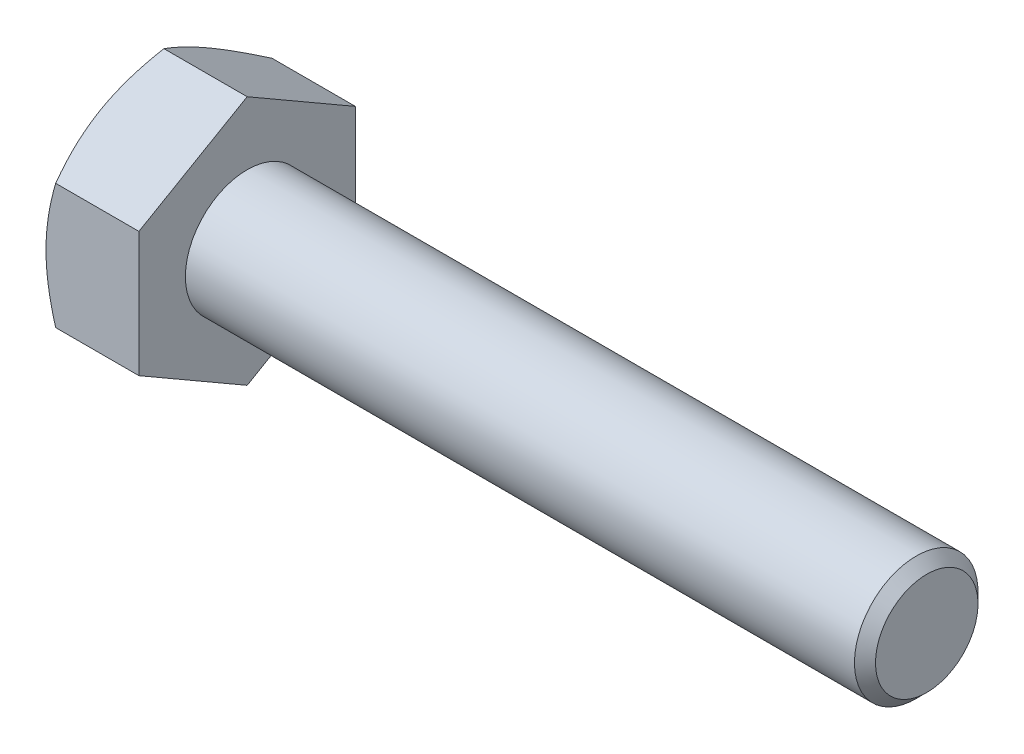
from build123d import *

# Parameters (mm, degrees)
BASEHEAD_DEPTH = 4.7752


with BuildPart() as part:
    # Sketch1 → BaseHead (new body)
    with BuildSketch(Plane(origin=(0, 0, 0), x_dir=(0, 0, -1), z_dir=(1, 0, 0))):
        Polygon((5.5626, 3.211568607), (5.5626, -3.211568607), (0, -6.423137215), (-5.5626, -3.211568607), (-5.5626, 3.211568607), (0, 6.423137215), align=None)
    extrude(amount=BASEHEAD_DEPTH)

    # BodySke → BaseBody (revolve)
    with BuildSketch(Plane.XY):
        Polygon((0, 0), (39.7002, 0), (39.7002, 2.63398), (39.15918, 3.175), (0, 3.175), align=None)
    revolve(axis=Axis((0, 0, 0), (1, 0, 0)))

    # Sketch3 → HeadChamfer (revolve, cut)
    with BuildSketch(Plane.XY):
        Polygon((0, 5.5626), (4.163005602, 12.773137215), (4.163005602, 19.123137215), (-12.7, 19.123137215), (-12.7, 5.5626), align=None)
    revolve(axis=Axis((0, 0, 0), (1, 0, 0)), mode=Mode.SUBTRACT)


solid = part.part
